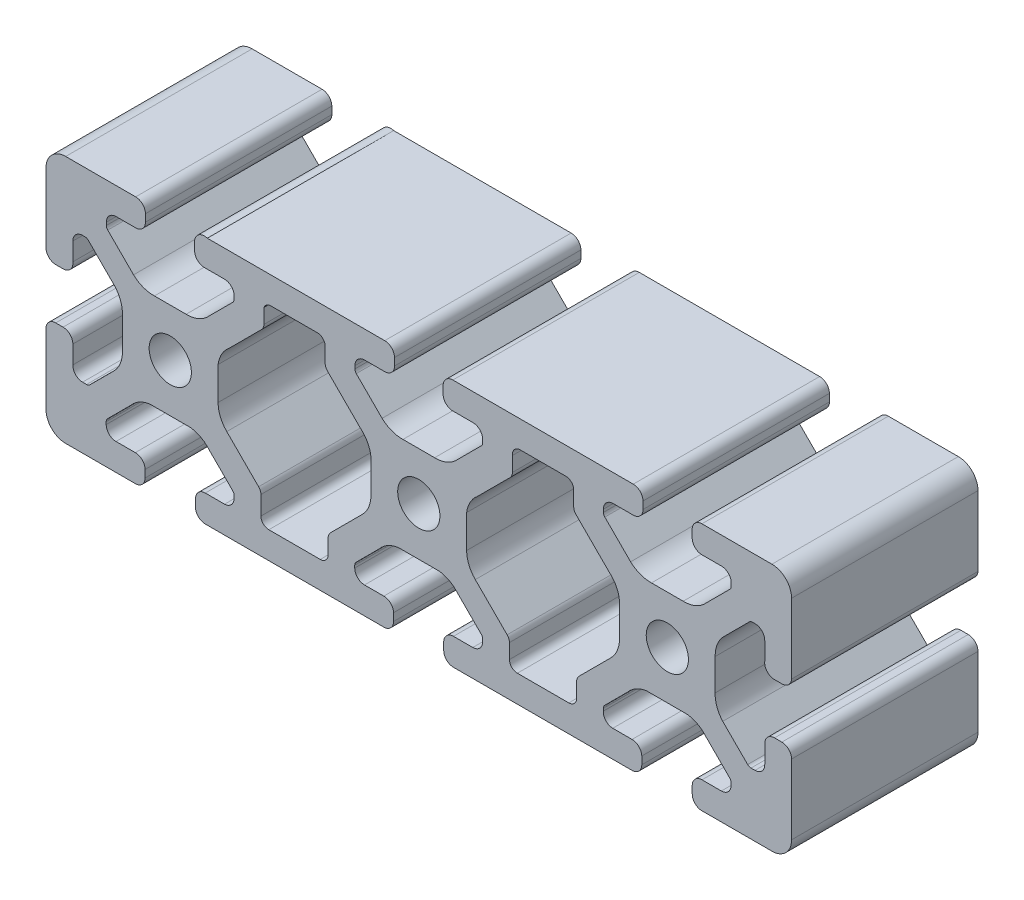
from build123d import *

# Parameters (mm, degrees)
SKETCH1_R      = 3.4
EXTRUDE1_DEPTH = 30


with BuildPart() as part:
    # Sketch1 → Extrude1 (new body)
    with BuildSketch(Plane.XY):
        with BuildLine():
            Line((-34.039664946, 20), (-5.483529002, 20))
            ThreePointArc((-5.483529002, 20), (-4.373371355, 19.540157646), (-3.913529002, 18.43))
            Line((-3.913529002, 18.43), (-3.913529002, 17.25))
            ThreePointArc((-3.913529002, 17.25), (-4.373371355, 16.139842354), (-5.483529002, 15.68))
            Line((-5.483529002, 15.68), (-8.715, 15.68))
            ThreePointArc((-8.715, 15.68), (-9.825157646, 15.220157646), (-10.285, 14.11))
            Line((-10.285, 14.11), (-10.285, 13.654503602))
            ThreePointArc((-10.285, 13.654503602), (-10.227148445, 13.363664194), (-10.062401154, 13.117102448))
            Line((-10.062401154, 13.117102448), (-5.908127218, 8.962828513))
            ThreePointArc((-5.908127218, 8.962828513), (-4.352583366, 8.002049766), (-2.549370008, 7.7))
            Line((-2.549370008, 7.7), (2.549370008, 7.7))
            ThreePointArc((2.549370008, 7.7), (4.352583366, 8.002049766), (5.908127218, 8.962828513))
            Line((5.908127218, 8.962828513), (10.062401154, 13.117102448))
            ThreePointArc((10.062401154, 13.117102448), (10.227148445, 13.363664194), (10.285, 13.654503602))
            Line((10.285, 13.654503602), (10.285, 14.11))
            ThreePointArc((10.285, 14.11), (9.825157646, 15.220157646), (8.715, 15.68))
            Line((8.715, 15.68), (5.481633908, 15.68))
            ThreePointArc((5.481633908, 15.68), (4.371476261, 16.139842354), (3.911633908, 17.25))
            Line((3.911633908, 17.25), (3.911633908, 18.43))
            ThreePointArc((3.911633908, 18.43), (4.371476261, 19.540157646), (5.481633908, 20))
            Line((5.481633908, 20), (34.516470998, 20))
            ThreePointArc((34.516470998, 20), (35.626628645, 19.540157646), (36.086470998, 18.43))
            Line((36.086470998, 18.43), (36.086470998, 17.25))
            ThreePointArc((36.086470998, 17.25), (35.626628645, 16.139842354), (34.516470998, 15.68))
            Line((34.516470998, 15.68), (31.285, 15.68))
            ThreePointArc((31.285, 15.68), (30.174842354, 15.220157646), (29.715, 14.11))
            Line((29.715, 14.11), (29.715, 13.654503602))
            ThreePointArc((29.715, 13.654503602), (29.772851555, 13.363664194), (29.937598846, 13.117102448))
            Line((29.937598846, 13.117102448), (34.091872782, 8.962828513))
            ThreePointArc((34.091872782, 8.962828513), (35.647416634, 8.002049766), (37.450629992, 7.7))
            Line((37.450629992, 7.7), (42.549370008, 7.7))
            ThreePointArc((42.549370008, 7.7), (44.352583366, 8.002049766), (45.908127218, 8.962828513))
            Line((45.908127218, 8.962828513), (50.062401154, 13.117102448))
            ThreePointArc((50.062401154, 13.117102448), (50.227148445, 13.363664194), (50.285, 13.654503602))
            Line((50.285, 13.654503602), (50.285, 14.11))
            ThreePointArc((50.285, 14.11), (49.825157646, 15.220157646), (48.715, 15.68))
            Line((48.715, 15.68), (45.569550674, 15.68))
            ThreePointArc((45.569550674, 15.68), (44.459393028, 16.139842354), (43.999550674, 17.25))
            Line((43.999550674, 17.25), (43.999550674, 18.43))
            ThreePointArc((43.999550674, 18.43), (44.459393028, 19.540157646), (45.569550674, 20))
            Line((45.569550674, 20), (53, 20))
            Line((53, 20), (56.83, 20))
            ThreePointArc((56.83, 20), (59.067780363, 19.075288119), (60, 16.840624931))
            Line((60, 16.840624931), (60, 13.010624931))
            Line((60, 13.010624931), (60, 5.582508737))
            ThreePointArc((60, 5.582508737), (59.463837117, 4.50713236), (58.324306777, 4.125850842))
            Line((58.324306777, 4.125850842), (57.144306777, 4.125850842))
            ThreePointArc((57.144306777, 4.125850842), (56.032016936, 4.688224348), (55.68, 5.883856704))
            Line((55.68, 5.883856704), (55.68, 8.786544652))
            ThreePointArc((55.68, 8.786544652), (55.220157646, 9.896702299), (54.11, 10.356544652))
            Line((54.11, 10.356544652), (53.726048254, 10.356544652))
            ThreePointArc((53.726048254, 10.356544652), (53.435208846, 10.298693097), (53.188647101, 10.133945806))
            Line((53.188647101, 10.133945806), (49.01112516, 5.956423865))
            ThreePointArc((49.01112516, 5.956423865), (48.019360521, 4.393900047), (47.7, 2.570966522))
            Line((47.7, 2.570966522), (47.7, -2.502014759))
            ThreePointArc((47.7, -2.502014759), (47.979996058, -4.299996729), (48.915473265, -5.86077197))
            Line((48.915473265, -5.86077197), (52.929133281, -9.874431986))
            ThreePointArc((52.929133281, -9.874431986), (53.175695026, -10.039179277), (53.466534434, -10.097030832))
            Line((53.466534434, -10.097030832), (54.110956402, -10.097030832))
            ThreePointArc((54.110956402, -10.097030832), (55.240319888, -9.617644474), (55.68, -8.472238622))
            Line((55.68, -8.472238622), (55.68, -5.569550674))
            ThreePointArc((55.68, -5.569550674), (56.139842354, -4.459393028), (57.25, -3.999550674))
            Line((57.25, -3.999550674), (58.43, -3.999550674))
            ThreePointArc((58.43, -3.999550674), (59.540157646, -4.459393028), (60, -5.569550674))
            Line((60, -5.569550674), (60, -13))
            Line((60, -13), (60, -16.83))
            ThreePointArc((60, -16.83), (59.134817946, -19.011326974), (57.006613773, -20))
            Line((57.006613773, -20), (53.176613773, -20))
            Line((53.176613773, -20), (45.746164447, -20))
            ThreePointArc((45.746164447, -20), (44.529723595, -19.606606664), (44.009186442, -18.438904761))
            Line((44.009186442, -18.438904761), (44.009186442, -17.209259175))
            ThreePointArc((44.009186442, -17.209259175), (44.483188152, -16.125346027), (45.579186442, -15.68))
            Line((45.579186442, -15.68), (48.689593221, -15.68))
            ThreePointArc((48.689593221, -15.68), (49.818956707, -15.200613642), (50.258636819, -14.05520779))
            Line((50.258636819, -14.05520779), (50.258636819, -13.719694805))
            ThreePointArc((50.258636819, -13.719694805), (50.200785264, -13.428855396), (50.036037973, -13.182293651))
            Line((50.036037973, -13.182293651), (46.258706785, -9.404962463))
            ThreePointArc((46.258706785, -9.404962463), (44.92885631, -8.297964566), (43.290732893, -7.740740825))
            Line((43.290732893, -7.740740825), (36.60763999, -7.740740825))
            ThreePointArc((36.60763999, -7.740740825), (34.969516573, -8.297964566), (33.639666098, -9.404962463))
            Line((33.639666098, -9.404962463), (29.911235665, -13.133392896))
            ThreePointArc((29.911235665, -13.133392896), (29.746488374, -13.379954641), (29.688636819, -13.670794049))
            Line((29.688636819, -13.670794049), (29.688636819, -14.05520779))
            ThreePointArc((29.688636819, -14.05520779), (30.111189478, -15.183383802), (31.208779662, -15.68))
            Line((31.208779662, -15.68), (34.319186442, -15.68))
            ThreePointArc((34.319186442, -15.68), (35.415184731, -16.125346027), (35.889186442, -17.209259175))
            Line((35.889186442, -17.209259175), (35.889186442, -18.43))
            ThreePointArc((35.889186442, -18.43), (35.429344088, -19.540157646), (34.319186442, -20))
            Line((34.319186442, -20), (25.940192472, -20))
            Line((25.940192472, -20), (21.729238859, -20))
            Line((21.729238859, -20), (13.958180411, -20))
            Line((13.958180411, -20), (5.579186442, -20))
            ThreePointArc((5.579186442, -20), (4.469028795, -19.540157646), (4.009186442, -18.43))
            Line((4.009186442, -18.43), (4.009186442, -17.209259175))
            ThreePointArc((4.009186442, -17.209259175), (4.483188152, -16.125346027), (5.579186442, -15.68))
            Line((5.579186442, -15.68), (8.689593221, -15.68))
            ThreePointArc((8.689593221, -15.68), (9.799750867, -15.220157646), (10.259593221, -14.11))
            Line((10.259593221, -14.11), (10.259593221, -13.670794049))
            ThreePointArc((10.259593221, -13.670794049), (10.201741665, -13.379954641), (10.036994374, -13.133392896))
            Line((10.036994374, -13.133392896), (6.308563942, -9.404962463))
            ThreePointArc((6.308563942, -9.404962463), (4.978713467, -8.297964566), (3.34059005, -7.740740825))
            Line((3.34059005, -7.740740825), (-3.342502853, -7.740740825))
            ThreePointArc((-3.342502853, -7.740740825), (-4.98062627, -8.297964566), (-6.310476745, -9.404962463))
            Line((-6.310476745, -9.404962463), (-10.087807933, -13.182293651))
            ThreePointArc((-10.087807933, -13.182293651), (-10.252555224, -13.428855396), (-10.310406779, -13.719694805))
            Line((-10.310406779, -13.719694805), (-10.310406779, -14.11))
            ThreePointArc((-10.310406779, -14.11), (-9.850564426, -15.220157646), (-8.740406779, -15.68))
            Line((-8.740406779, -15.68), (-5.63, -15.68))
            ThreePointArc((-5.63, -15.68), (-4.534001711, -16.125346027), (-4.06, -17.209259175))
            Line((-4.06, -17.209259175), (-4.06, -18.43))
            ThreePointArc((-4.06, -18.43), (-4.519842354, -19.540157646), (-5.63, -20))
            Line((-5.63, -20), (-14.00899397, -20))
            Line((-14.00899397, -20), (-21.780052417, -20))
            Line((-21.780052417, -20), (-25.99100603, -20))
            Line((-25.99100603, -20), (-34.37, -20))
            ThreePointArc((-34.37, -20), (-35.480157646, -19.540157646), (-35.94, -18.43))
            Line((-35.94, -18.43), (-35.94, -17.25))
            ThreePointArc((-35.94, -17.25), (-35.480157646, -16.139842354), (-34.37, -15.68))
            Line((-34.37, -15.68), (-31.259593221, -15.68))
            ThreePointArc((-31.259593221, -15.68), (-30.18116243, -15.203502372), (-29.73846722, -14.110760907))
            Line((-29.73846722, -14.110760907), (-29.73846722, -13.672733609))
            ThreePointArc((-29.73846722, -13.672733609), (-29.796318775, -13.3818942), (-29.961066066, -13.135332455))
            Line((-29.961066066, -13.135332455), (-33.691436058, -9.404962463))
            ThreePointArc((-33.691436058, -9.404962463), (-35.021286533, -8.297964566), (-36.65940995, -7.740740825))
            Line((-36.65940995, -7.740740825), (-43.342502853, -7.740740825))
            ThreePointArc((-43.342502853, -7.740740825), (-44.98062627, -8.297964566), (-46.310476745, -9.404962463))
            Line((-46.310476745, -9.404962463), (-50.087807933, -13.182293651))
            ThreePointArc((-50.087807933, -13.182293651), (-50.252555224, -13.428855396), (-50.310406779, -13.719694805))
            Line((-50.310406779, -13.719694805), (-50.310406779, -14.11))
            ThreePointArc((-50.310406779, -14.11), (-49.850564426, -15.220157646), (-48.740406779, -15.68))
            Line((-48.740406779, -15.68), (-45.63, -15.68))
            ThreePointArc((-45.63, -15.68), (-44.519842354, -16.139842354), (-44.06, -17.25))
            Line((-44.06, -17.25), (-44.06, -18.438904761))
            ThreePointArc((-44.06, -18.438904761), (-44.580537154, -19.606606664), (-45.796978006, -20))
            Line((-45.796978006, -20), (-53.227427332, -20))
            Line((-53.227427332, -20), (-57.057427332, -20))
            ThreePointArc((-57.057427332, -20), (-59.153330856, -18.99480488), (-60, -16.83))
            Line((-60, -16.83), (-60, -13))
            Line((-60, -13), (-60, -5.569550674))
            ThreePointArc((-60, -5.569550674), (-59.540157646, -4.459393028), (-58.43, -3.999550674))
            Line((-58.43, -3.999550674), (-57.25, -3.999550674))
            ThreePointArc((-57.25, -3.999550674), (-56.139842354, -4.459393028), (-55.68, -5.569550674))
            Line((-55.68, -5.569550674), (-55.68, -8.472238622))
            ThreePointArc((-55.68, -8.472238622), (-55.240319888, -9.617644474), (-54.110956402, -10.097030832))
            Line((-54.110956402, -10.097030832), (-53.466534434, -10.097030832))
            ThreePointArc((-53.466534434, -10.097030832), (-53.175695026, -10.039179277), (-52.929133281, -9.874431986))
            Line((-52.929133281, -9.874431986), (-48.915473265, -5.86077197))
            ThreePointArc((-48.915473265, -5.86077197), (-47.979996058, -4.299996729), (-47.7, -2.502014759))
            Line((-47.7, -2.502014759), (-47.7, 2.570966522))
            ThreePointArc((-47.7, 2.570966522), (-48.019360521, 4.393900047), (-49.01112516, 5.956423865))
            Line((-49.01112516, 5.956423865), (-53.188647101, 10.133945806))
            ThreePointArc((-53.188647101, 10.133945806), (-53.435208846, 10.298693097), (-53.726048254, 10.356544652))
            Line((-53.726048254, 10.356544652), (-54.11, 10.356544652))
            ThreePointArc((-54.11, 10.356544652), (-55.220157646, 9.896702299), (-55.68, 8.786544652))
            Line((-55.68, 8.786544652), (-55.68, 5.883856704))
            ThreePointArc((-55.68, 5.883856704), (-56.032016936, 4.688224348), (-57.144306777, 4.125850842))
            Line((-57.144306777, 4.125850842), (-58.324306777, 4.125850842))
            ThreePointArc((-58.324306777, 4.125850842), (-59.463837117, 4.50713236), (-60, 5.582508737))
            Line((-60, 5.582508737), (-60, 13.010624931))
            Line((-60, 13.010624931), (-60, 16.840624931))
            ThreePointArc((-60, 16.840624931), (-59.067780363, 19.075288119), (-56.83, 20))
            Line((-56.83, 20), (-53, 20))
            Line((-53, 20), (-45.569550674, 20))
            ThreePointArc((-45.569550674, 20), (-44.459393028, 19.540157646), (-43.999550674, 18.43))
            Line((-43.999550674, 18.43), (-43.999550674, 17.25))
            ThreePointArc((-43.999550674, 17.25), (-44.459393028, 16.139842354), (-45.569550674, 15.68))
            Line((-45.569550674, 15.68), (-48.715, 15.68))
            ThreePointArc((-48.715, 15.68), (-49.825157646, 15.220157646), (-50.285, 14.11))
            Line((-50.285, 14.11), (-50.285, 13.654503602))
            ThreePointArc((-50.285, 13.654503602), (-50.227148445, 13.363664194), (-50.062401154, 13.117102448))
            Line((-50.062401154, 13.117102448), (-45.908127218, 8.962828513))
            ThreePointArc((-45.908127218, 8.962828513), (-44.352583366, 8.002049766), (-42.549370008, 7.7))
            Line((-42.549370008, 7.7), (-37.450629992, 7.7))
            ThreePointArc((-37.450629992, 7.7), (-35.647416634, 8.002049766), (-34.091872782, 8.962828513))
            Line((-34.091872782, 8.962828513), (-29.937598846, 13.117102448))
            ThreePointArc((-29.937598846, 13.117102448), (-29.772851555, 13.363664194), (-29.715, 13.654503602))
            Line((-29.715, 13.654503602), (-29.715, 14.11))
            ThreePointArc((-29.715, 14.11), (-30.174842354, 15.220157646), (-31.285, 15.68))
            Line((-31.285, 15.68), (-34.516469227, 15.68))
            ThreePointArc((-34.516469227, 15.68), (-35.625793929, 16.139008264), (-36.086469227, 17.247641725))
            Line((-36.086469227, 17.247641725), (-36.086469227, 18.427641725))
            ThreePointArc((-36.086469227, 18.427641725), (-35.474804984, 19.749797238), (-34.039664946, 20))
        make_face()
        with Locations((-40, 0)):
            Circle(SKETCH1_R, mode=Mode.SUBTRACT)
        Circle(SKETCH1_R, mode=Mode.SUBTRACT)
        with Locations((40, 0)):
            Circle(SKETCH1_R, mode=Mode.SUBTRACT)
        with BuildLine():
            Line((-16.336610335, 15.68), (-23.663389665, 15.68))
            ThreePointArc((-23.663389665, 15.68), (-24.423528742, 15.498374024), (-24.933389665, 14.906055487))
            Line((-24.933389665, 14.906055487), (-24.933389665, 12.537960264))
            ThreePointArc((-24.933389665, 12.537960264), (-25.030062659, 12.051952305), (-25.305364053, 11.639934652))
            Line((-25.305364053, 11.639934652), (-30.598777023, 6.346521682))
            ThreePointArc((-30.598777023, 6.346521682), (-31.746399861, 4.966462595), (-32.3, 3.259087959))
            Line((-32.3, 3.259087959), (-32.3, -2.025205833))
            ThreePointArc((-32.3, -2.025205833), (-31.938427779, -3.842952137), (-30.908757211, -5.383963044))
            Line((-30.908757211, -5.383963044), (-25.78141954, -10.511300715))
            ThreePointArc((-25.78141954, -10.511300715), (-25.506118146, -10.923318368), (-25.409445152, -11.409326327))
            Line((-25.409445152, -11.409326327), (-25.409445152, -14.41))
            ThreePointArc((-25.409445152, -14.41), (-25.037470764, -15.308025612), (-24.139445152, -15.68))
            Line((-24.139445152, -15.68), (-15.860554848, -15.68))
            ThreePointArc((-15.860554848, -15.68), (-14.962529236, -15.308025612), (-14.590554848, -14.41))
            Line((-14.590554848, -14.41), (-14.590554848, -12.041904777))
            ThreePointArc((-14.590554848, -12.041904777), (-14.493881854, -11.555896818), (-14.21858046, -11.143879165))
            Line((-14.21858046, -11.143879165), (-9.091242789, -6.016541495))
            ThreePointArc((-9.091242789, -6.016541495), (-8.061572221, -4.475530588), (-7.7, -2.657784284))
            Line((-7.7, -2.657784284), (-7.7, 2.626509509))
            ThreePointArc((-7.7, 2.626509509), (-8.229034521, 4.408178136), (-9.401222977, 5.850466196))
            Line((-9.401222977, 5.850466196), (-14.694635947, 11.143879165))
            ThreePointArc((-14.694635947, 11.143879165), (-14.969937341, 11.555896818), (-15.066610335, 12.041904777))
            Line((-15.066610335, 12.041904777), (-15.066610335, 14.41))
            ThreePointArc((-15.066610335, 14.41), (-15.438584723, 15.308025612), (-16.336610335, 15.68))
        make_face(mode=Mode.SUBTRACT)
        with BuildLine():
            Line((15.066610335, 14.273477036), (15.066610335, 11.905381813))
            ThreePointArc((15.066610335, 11.905381813), (14.969937341, 11.419373854), (14.694635947, 11.007356201))
            Line((14.694635947, 11.007356201), (9.401222977, 5.713943232))
            ThreePointArc((9.401222977, 5.713943232), (8.253600139, 4.333884145), (7.7, 2.626509509))
            Line((7.7, 2.626509509), (7.7, -2.657784284))
            ThreePointArc((7.7, -2.657784284), (8.061572221, -4.475530588), (9.091242789, -6.016541495))
            Line((9.091242789, -6.016541495), (14.21858046, -11.143879165))
            ThreePointArc((14.21858046, -11.143879165), (14.493881854, -11.555896818), (14.590554848, -12.041904777))
            Line((14.590554848, -12.041904777), (14.590554848, -14.41))
            ThreePointArc((14.590554848, -14.41), (14.962529236, -15.308025612), (15.860554848, -15.68))
            Line((15.860554848, -15.68), (24.139445152, -15.68))
            ThreePointArc((24.139445152, -15.68), (25.037470764, -15.308025612), (25.409445152, -14.41))
            Line((25.409445152, -14.41), (25.409445152, -12.041904777))
            ThreePointArc((25.409445152, -12.041904777), (25.506118146, -11.555896818), (25.78141954, -11.143879165))
            Line((25.78141954, -11.143879165), (30.908757211, -6.016541495))
            ThreePointArc((30.908757211, -6.016541495), (31.938427779, -4.475530588), (32.3, -2.657784284))
            Line((32.3, -2.657784284), (32.3, 2.626509509))
            ThreePointArc((32.3, 2.626509509), (31.770965479, 4.408178136), (30.598777023, 5.850466196))
            Line((30.598777023, 5.850466196), (25.305364053, 11.143879165))
            ThreePointArc((25.305364053, 11.143879165), (25.030062659, 11.555896818), (24.933389665, 12.041904777))
            Line((24.933389665, 12.041904777), (24.933389665, 14.41))
            ThreePointArc((24.933389665, 14.41), (24.561415277, 15.308025612), (23.663389665, 15.68))
            Line((23.663389665, 15.68), (16.336610335, 15.68))
            ThreePointArc((16.336610335, 15.68), (15.386642405, 15.261134351), (15.066610335, 14.273477036))
        make_face(mode=Mode.SUBTRACT)
    extrude(amount=-EXTRUDE1_DEPTH)


solid = part.part
